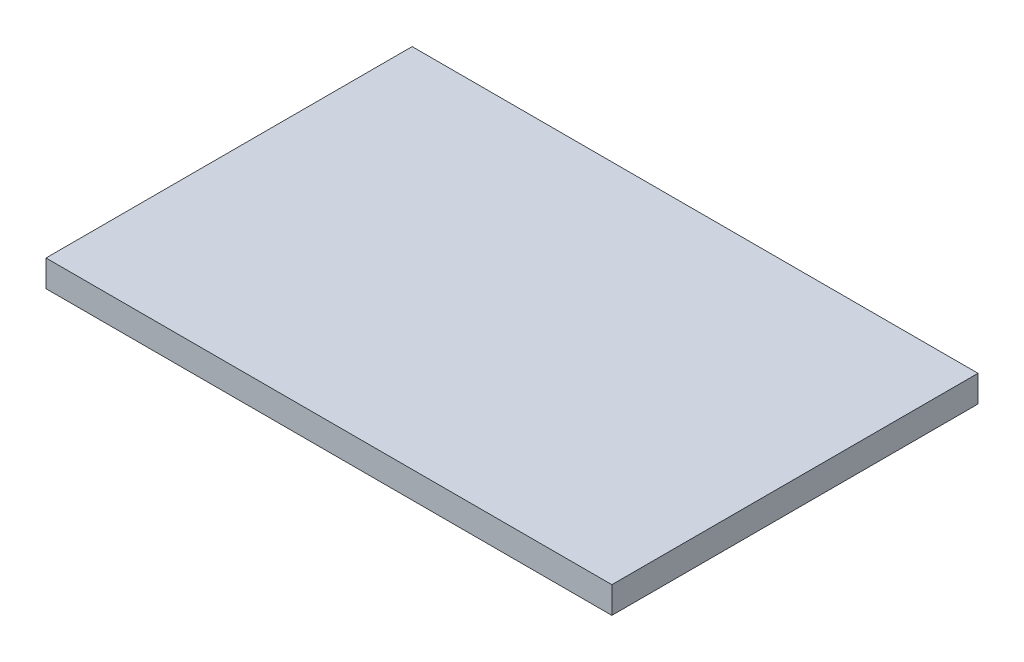
from build123d import *

# Parameters (mm, degrees)
SKETCH_1_W      = 85
SKETCH_1_H      = 55
EXTRUDE_1_DEPTH = 4


with BuildPart() as part:
    # 草图1 → 凸台-拉伸1 (new body)
    with BuildSketch(Plane(origin=(0, 0, 0), x_dir=(1, 0, 0), z_dir=(0, 1, 0))):
        with Locations((42.5, -27.5)):
            Rectangle(SKETCH_1_W, SKETCH_1_H)
    extrude(amount=EXTRUDE_1_DEPTH)


solid = part.part
